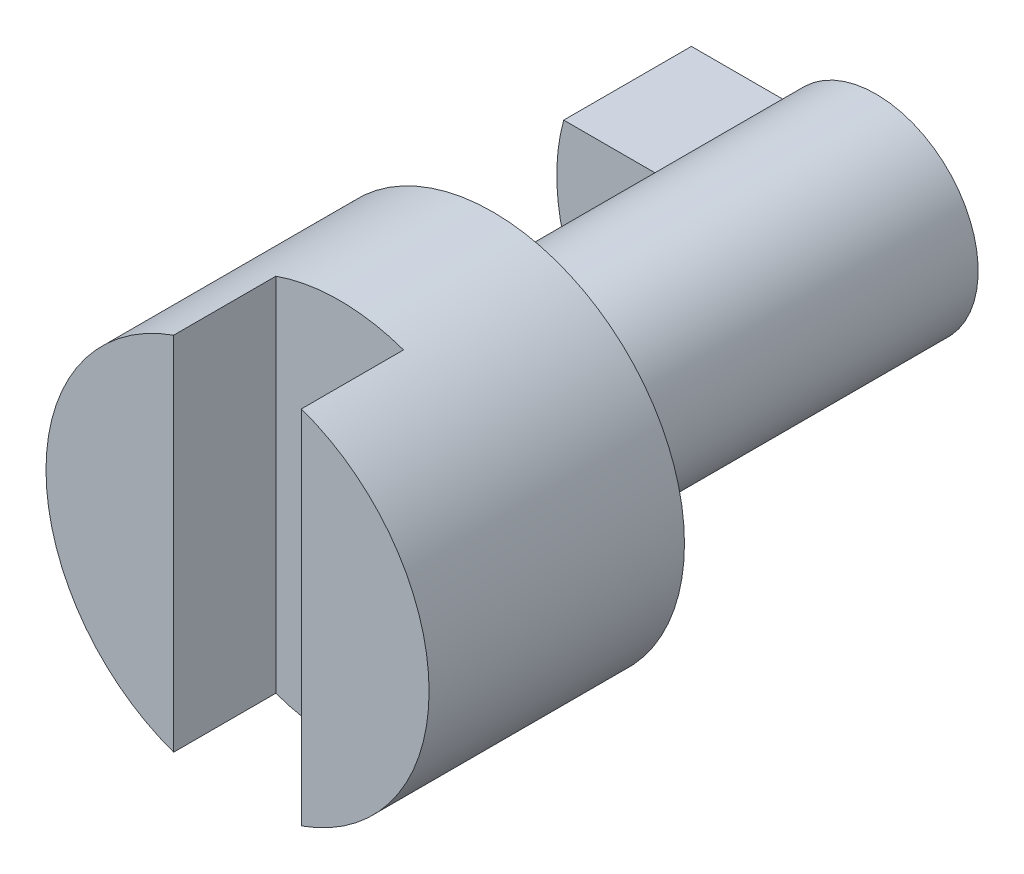
from build123d import *

# Parameters (mm, degrees)
SKETCH1_R           = 7.5
BOSS_EXTRUDE1_DEPTH = 10
SKETCH2_R           = 4
BOSS_EXTRUDE2_DEPTH = 15
BOSS_EXTRUDE3_DEPTH = 5
SKETCH4_W           = 5
SKETCH4_H           = 49.018189619
CUT_EXTRUDE1_DEPTH  = 4


with BuildPart() as part:
    # Sketch1 → Boss-Extrude1 (new body)
    with BuildSketch(Plane.XY):
        Circle(SKETCH1_R)
    extrude(amount=BOSS_EXTRUDE1_DEPTH)

    # Sketch2 → Boss-Extrude2 (add)
    with BuildSketch(Plane(origin=(0, 0, 0), x_dir=(-1, 0, 0), z_dir=(0, 0, -1))):
        Circle(SKETCH2_R)
    extrude(amount=BOSS_EXTRUDE2_DEPTH)

    # Sketch4 → Cut-Extrude1 (cut)
    with BuildSketch(Plane.XY.offset(10)):
        with Locations((0, 10.94373623)):
            Rectangle(SKETCH4_W, SKETCH4_H)
    extrude(amount=-CUT_EXTRUDE1_DEPTH, mode=Mode.SUBTRACT)


with BuildPart() as body_2:
    # Sketch3 → Boss-Extrude3 (new body)
    with BuildSketch(Plane(origin=(0, 0, -15), x_dir=(-1, 0, 0), z_dir=(0, 0, -1))):
        with BuildLine():
            Line((7.228416147, 2), (3.464101615, 2))
            ThreePointArc((3.464101615, 2), (3.863703305, 1.03527618), (4, 0))
            ThreePointArc((4, 0), (3.863703305, -1.03527618), (3.464101615, -2))
            Line((3.464101615, -2), (7.228416147, -2))
            ThreePointArc((7.228416147, -2), (7.5, 0), (7.228416147, 2))
        make_face()
    extrude(amount=-BOSS_EXTRUDE3_DEPTH)


solid = Compound([part.part, body_2.part])
